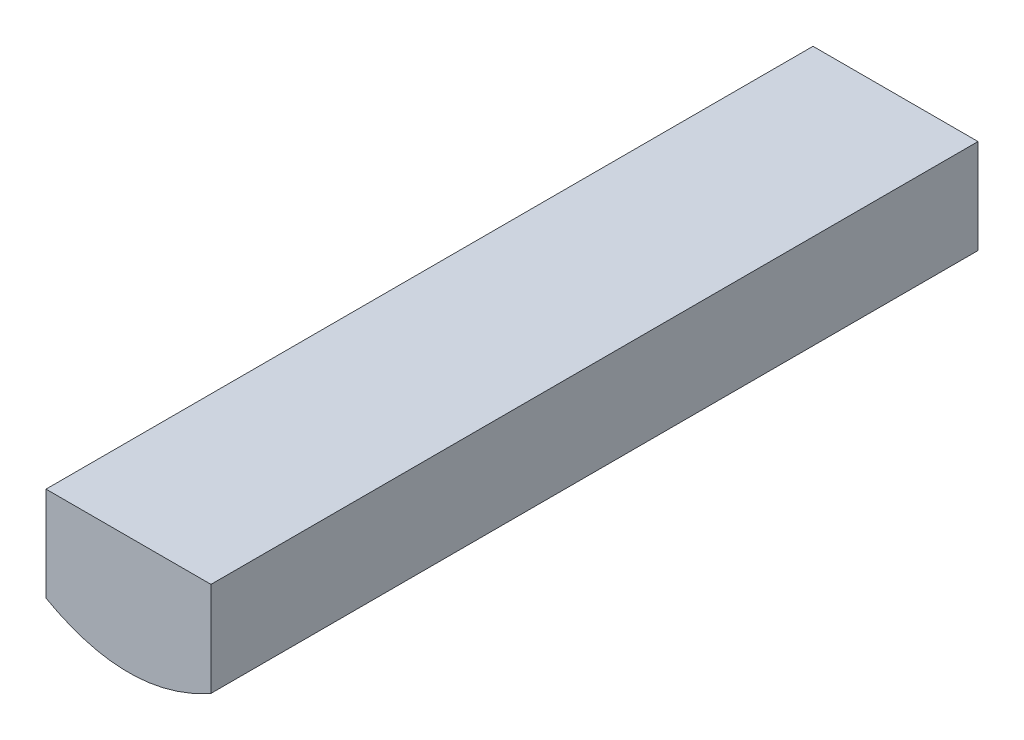
from build123d import *

# Parameters (mm, degrees)
BOSS_EXTRUDE2_DEPTH = 331.382
SKETCH5_W           = 260
SKETCH5_H           = 120
CUT_EXTRUDE4_DEPTH  = 332.3820001
SKETCH6_W           = 71.274118724
SKETCH6_H           = 40.8
BOSS_EXTRUDE3_DEPTH = 331.382


with BuildPart() as part:
    # Sketch2 → Boss-Extrude2 (new body)
    with BuildSketch(Plane.XY):
        with BuildLine():
            Line((-127, 127), (127, 127))
            add(Edge.make_bspline(
                [(-127, 127), (0, -127), (127, 127)],
                knots=[0.056028396, 0.056028396, 0.056028396, 0.943971604, 0.943971604, 0.943971604], degree=2))
        make_face()
    extrude(amount=BOSS_EXTRUDE2_DEPTH)

    # Sketch5 → Cut-Extrude4 (cut, through all)
    with BuildSketch(Plane.XY.offset(331.382)):
        with Locations((0, 70)):
            Rectangle(SKETCH5_W, SKETCH5_H)
    extrude(amount=-CUT_EXTRUDE4_DEPTH, mode=Mode.SUBTRACT)

    # Sketch6 → Boss-Extrude3 (add)
    with BuildSketch(Plane.XY.offset(331.382)):
        with Locations((0, 30.4)):
            Rectangle(SKETCH6_W, SKETCH6_H)
    extrude(amount=-BOSS_EXTRUDE3_DEPTH)


solid = part.part
